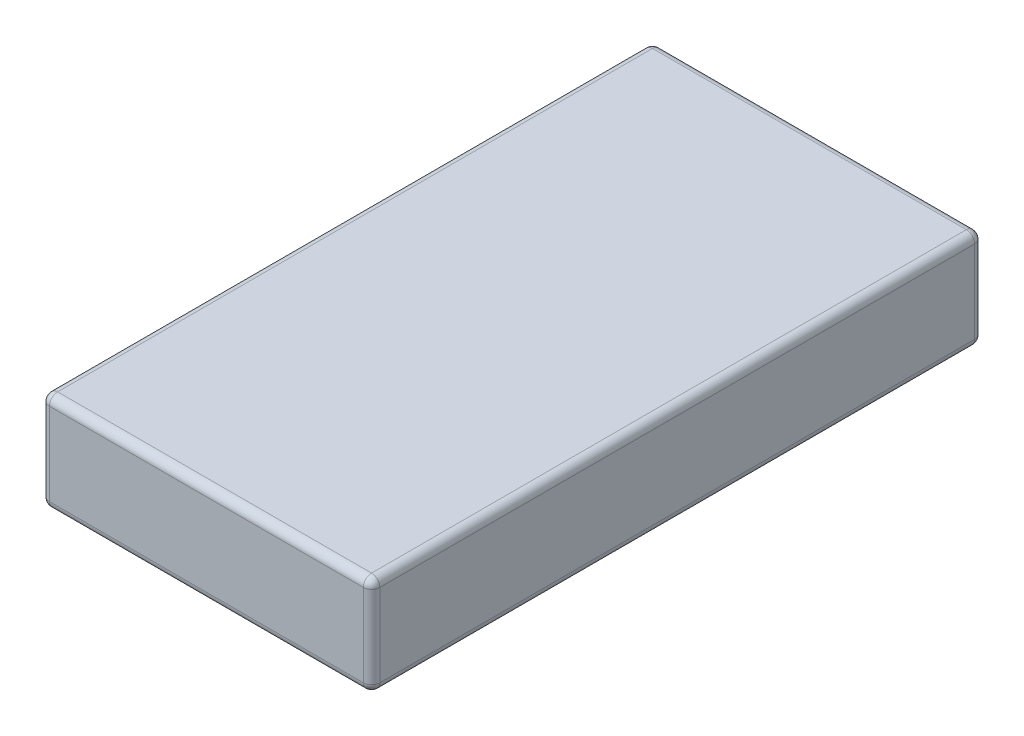
from build123d import *

# Parameters (mm, degrees)
SKETCH1_W           = 20
SKETCH1_H           = 37
BOSS_EXTRUDE1_DEPTH = 6
FILLET1_R           = 0.5


with BuildPart() as part:
    # Sketch1 → Boss-Extrude1 (new body)
    with BuildSketch(Plane(origin=(0, 0, 0), x_dir=(1, 0, 0), z_dir=(0, 1, 0))):
        Rectangle(SKETCH1_W, SKETCH1_H)
    extrude(amount=BOSS_EXTRUDE1_DEPTH)

    # Fillet1
    fillet1_edges = [part.edges().sort_by_distance(p)[0] for p in [
        (-10, 6, 0),
        (0, 6, 18.5),
        (10, 6, 0),
        (0, 0, 18.5),
        (-10, 0, 0),
        (0, 0, -18.5),
        (10, 0, 0),
        (10, 3, 18.5),
        (-10, 3, 18.5),
        (-10, 3, -18.5),
        (10, 3, -18.5),
        (0, 6, -18.5),
    ]]
    fillet(fillet1_edges, radius=FILLET1_R)


solid = part.part
